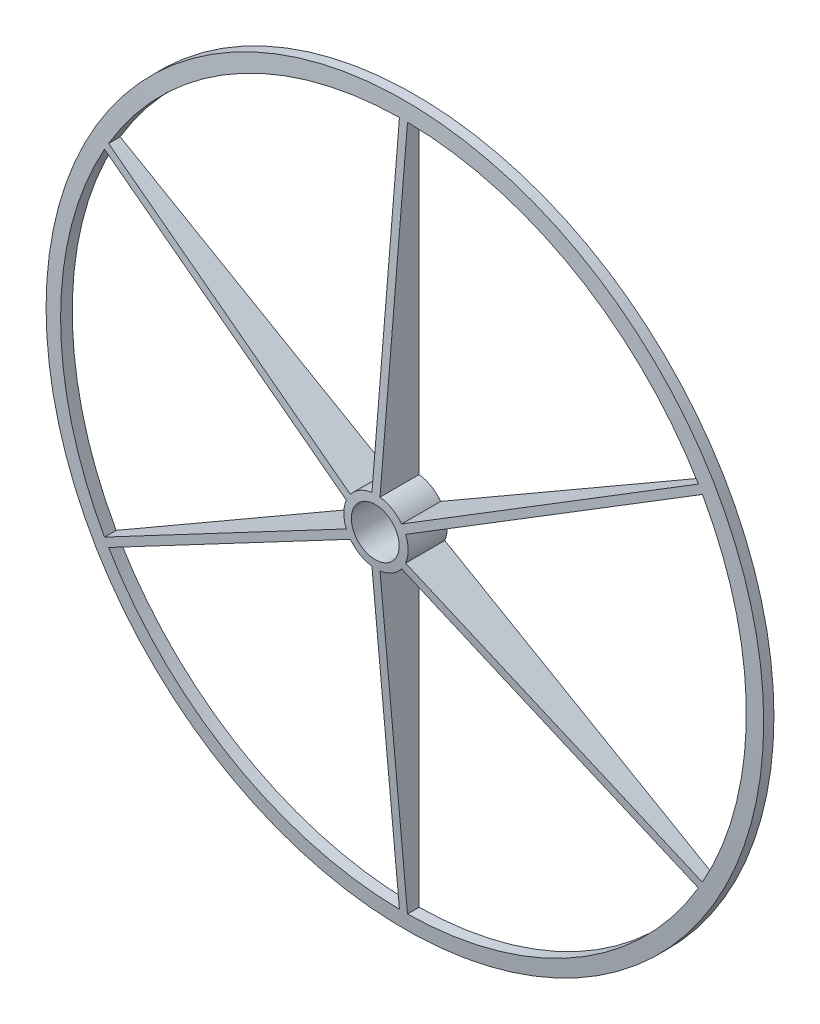
from build123d import *

# Parameters (mm, degrees)
CUT_EXTRUDE1_DEPTH = 127
SKETCH3_R          = 6.35
CUT_EXTRUDE2_DEPTH = 127


with BuildPart() as part:
    # Sketch1 → Revolve1 (revolve)
    with BuildSketch(Plane(origin=(0, 0, 0), x_dir=(1, 0, 0), z_dir=(0, 1, 0))):
        Polygon((0, 27.715882353), (0, -35.784117647), (-533.4, 11.43), (-533.4, 27.715882353), align=None)
    revolve(axis=Axis((38.1, 0, -15.015882353), (0, 0, 1)))

    # Sketch2 → Cut-Extrude1 (cut)
    with BuildSketch(Plane(origin=(0, 0, -27.715882353), x_dir=(-1, 0, 0), z_dir=(0, 0, -1))):
        with BuildLine():
            ThreePointArc((-85.306443453, -19.836041494), (-89.304656484, 0), (-85.306443453, 19.836041494))
            Line((-85.306443453, 19.836041494), (-514.216095648, 267.467144646))
            ThreePointArc((-514.216095648, 267.467144646), (-584.2, 0), (-514.216095648, -267.467144646))
            Line((-514.216095648, -267.467144646), (-85.306443453, -19.836041494))
        make_face()
        with BuildLine():
            ThreePointArc((-78.881737571, 30.963958506), (-63.702328242, 44.344533307), (-44.524705882, 50.8))
            Line((-44.524705882, 50.8), (-44.524705882, 546.062206305))
            ThreePointArc((-44.524705882, 546.062206305), (-311.15, 472.936473007), (-507.791389765, 278.595061658))
            Line((-507.791389765, 278.595061658), (-78.881737571, 30.963958506))
        make_face()
        with BuildLine():
            Line((-31.675294118, 546.062206305), (-31.675294118, 50.8))
            ThreePointArc((-31.675294118, 50.8), (-12.497671758, 44.344533307), (2.681737571, 30.963958506))
            Line((2.681737571, 30.963958506), (431.591389765, 278.595061658))
            ThreePointArc((431.591389765, 278.595061658), (234.95, 472.936473007), (-31.675294118, 546.062206305))
        make_face()
        with BuildLine():
            ThreePointArc((9.106443453, 19.836041494), (13.104656484, 0), (9.106443453, -19.836041494))
            Line((9.106443453, -19.836041494), (438.016095648, -267.467144646))
            ThreePointArc((438.016095648, -267.467144646), (508, 0), (438.016095648, 267.467144646))
            Line((438.016095648, 267.467144646), (9.106443453, 19.836041494))
        make_face()
        with BuildLine():
            ThreePointArc((2.681737571, -30.963958506), (-12.497671758, -44.344533307), (-31.675294118, -50.8))
            Line((-31.675294118, -50.8), (-31.675294118, -546.062206305))
            ThreePointArc((-31.675294118, -546.062206305), (234.95, -472.936473007), (431.591389765, -278.595061658))
            Line((431.591389765, -278.595061658), (2.681737571, -30.963958506))
        make_face()
        with BuildLine():
            ThreePointArc((-44.524705882, -50.8), (-63.702328242, -44.344533307), (-78.881737571, -30.963958506))
            Line((-78.881737571, -30.963958506), (-507.791389765, -278.595061658))
            ThreePointArc((-507.791389765, -278.595061658), (-311.15, -472.936473007), (-44.524705882, -546.062206305))
            Line((-44.524705882, -546.062206305), (-44.524705882, -50.8))
        make_face()
    extrude(amount=-CUT_EXTRUDE1_DEPTH, mode=Mode.SUBTRACT)

    # Sketch3 → Cut-Extrude2 (cut)
    with BuildSketch(Plane.XY):
        with Locations((982.963055161, 544.767048731)):
            Circle(SKETCH3_R)
        with Locations((963.263630927, -578.887452386)):
            Circle(SKETCH3_R)
        with Locations((-19.699424235, -1123.654501117)):
            Circle(SKETCH3_R)
        with Locations((-982.963055161, -544.767048731)):
            Circle(SKETCH3_R)
        with Locations((-963.263630927, 578.887452386)):
            Circle(SKETCH3_R)
        with Locations((19.699424235, 1123.654501117)):
            Circle(SKETCH3_R)
    extrude(amount=-CUT_EXTRUDE2_DEPTH, mode=Mode.SUBTRACT)


solid = part.part
